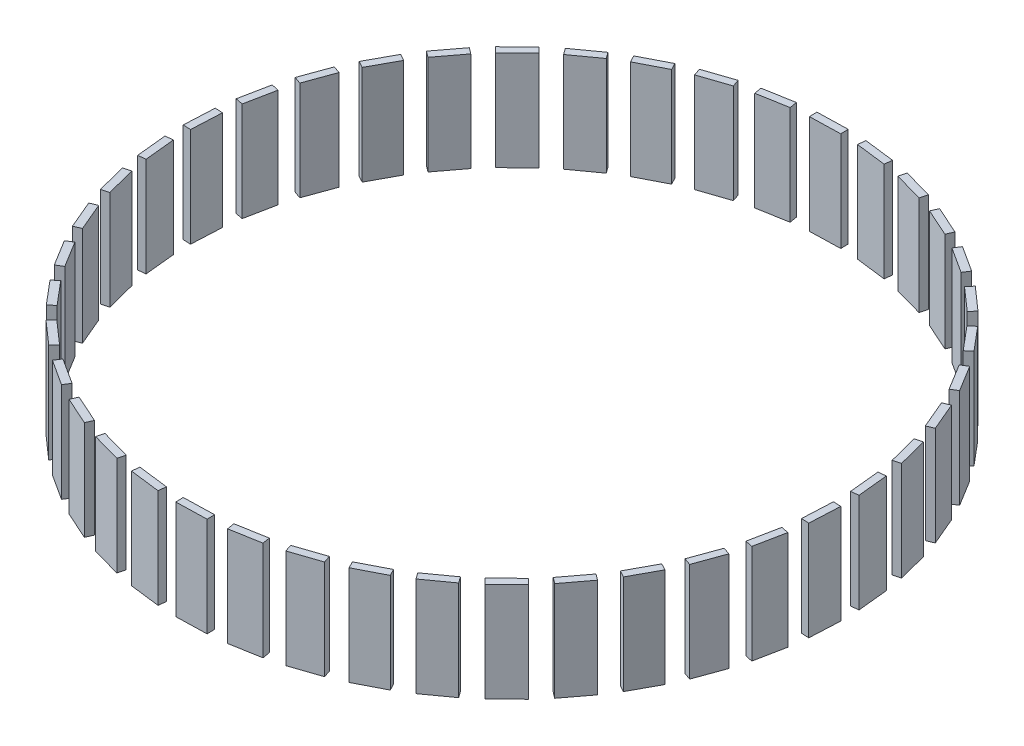
from build123d import *

# Parameters (mm, degrees)
SKETCH2_W           = 3.999993955
SKETCH2_H           = 13
BOSS_EXTRUDE1_DEPTH = 1
CIRPATTERN1_COUNT   = 42


with BuildPart() as part:
    # Sketch2 → Boss-Extrude1 (new body)
    with BuildSketch(Plane(origin=(54.639335118, 5.51e-07, -23.098494143), x_dir=(0.389380498, 3.69e-07, 0.921076993), z_dir=(-0.921076993, -9e-09, 0.389380498))):
        with Locations((82.503755349, 50.681860637)):
            Rectangle(SKETCH2_W, SKETCH2_H)
    extrude(amount=BOSS_EXTRUDE1_DEPTH)


with BuildPart() as cirpattern1_1:
    # CirPattern1: pattern copy
    add(part.part.rotate(Axis((47.084682439, 0, 69.668306924), (0, 1, 0)), 1 * 360 / CIRPATTERN1_COUNT))


with BuildPart() as cirpattern1_2:
    # CirPattern1: pattern copy
    add(part.part.rotate(Axis((47.084682439, 0, 69.668306924), (0, 1, 0)), 2 * 360 / CIRPATTERN1_COUNT))


with BuildPart() as cirpattern1_3:
    # CirPattern1: pattern copy
    add(part.part.rotate(Axis((47.084682439, 0, 69.668306924), (0, 1, 0)), 3 * 360 / CIRPATTERN1_COUNT))


with BuildPart() as cirpattern1_4:
    # CirPattern1: pattern copy
    add(part.part.rotate(Axis((47.084682439, 0, 69.668306924), (0, 1, 0)), 4 * 360 / CIRPATTERN1_COUNT))


with BuildPart() as cirpattern1_5:
    # CirPattern1: pattern copy
    add(part.part.rotate(Axis((47.084682439, 0, 69.668306924), (0, 1, 0)), 5 * 360 / CIRPATTERN1_COUNT))


with BuildPart() as cirpattern1_6:
    # CirPattern1: pattern copy
    add(part.part.rotate(Axis((47.084682439, 0, 69.668306924), (0, 1, 0)), 6 * 360 / CIRPATTERN1_COUNT))


with BuildPart() as cirpattern1_7:
    # CirPattern1: pattern copy
    add(part.part.rotate(Axis((47.084682439, 0, 69.668306924), (0, 1, 0)), 7 * 360 / CIRPATTERN1_COUNT))


with BuildPart() as cirpattern1_8:
    # CirPattern1: pattern copy
    add(part.part.rotate(Axis((47.084682439, 0, 69.668306924), (0, 1, 0)), 8 * 360 / CIRPATTERN1_COUNT))


with BuildPart() as cirpattern1_9:
    # CirPattern1: pattern copy
    add(part.part.rotate(Axis((47.084682439, 0, 69.668306924), (0, 1, 0)), 9 * 360 / CIRPATTERN1_COUNT))


with BuildPart() as cirpattern1_10:
    # CirPattern1: pattern copy
    add(part.part.rotate(Axis((47.084682439, 0, 69.668306924), (0, 1, 0)), 10 * 360 / CIRPATTERN1_COUNT))


with BuildPart() as cirpattern1_11:
    # CirPattern1: pattern copy
    add(part.part.rotate(Axis((47.084682439, 0, 69.668306924), (0, 1, 0)), 11 * 360 / CIRPATTERN1_COUNT))


with BuildPart() as cirpattern1_12:
    # CirPattern1: pattern copy
    add(part.part.rotate(Axis((47.084682439, 0, 69.668306924), (0, 1, 0)), 12 * 360 / CIRPATTERN1_COUNT))


with BuildPart() as cirpattern1_13:
    # CirPattern1: pattern copy
    add(part.part.rotate(Axis((47.084682439, 0, 69.668306924), (0, 1, 0)), 13 * 360 / CIRPATTERN1_COUNT))


with BuildPart() as cirpattern1_14:
    # CirPattern1: pattern copy
    add(part.part.rotate(Axis((47.084682439, 0, 69.668306924), (0, 1, 0)), 14 * 360 / CIRPATTERN1_COUNT))


with BuildPart() as cirpattern1_15:
    # CirPattern1: pattern copy
    add(part.part.rotate(Axis((47.084682439, 0, 69.668306924), (0, 1, 0)), 15 * 360 / CIRPATTERN1_COUNT))


with BuildPart() as cirpattern1_16:
    # CirPattern1: pattern copy
    add(part.part.rotate(Axis((47.084682439, 0, 69.668306924), (0, 1, 0)), 16 * 360 / CIRPATTERN1_COUNT))


with BuildPart() as cirpattern1_17:
    # CirPattern1: pattern copy
    add(part.part.rotate(Axis((47.084682439, 0, 69.668306924), (0, 1, 0)), 17 * 360 / CIRPATTERN1_COUNT))


with BuildPart() as cirpattern1_18:
    # CirPattern1: pattern copy
    add(part.part.rotate(Axis((47.084682439, 0, 69.668306924), (0, 1, 0)), 18 * 360 / CIRPATTERN1_COUNT))


with BuildPart() as cirpattern1_19:
    # CirPattern1: pattern copy
    add(part.part.rotate(Axis((47.084682439, 0, 69.668306924), (0, 1, 0)), 19 * 360 / CIRPATTERN1_COUNT))


with BuildPart() as cirpattern1_20:
    # CirPattern1: pattern copy
    add(part.part.rotate(Axis((47.084682439, 0, 69.668306924), (0, 1, 0)), 20 * 360 / CIRPATTERN1_COUNT))


with BuildPart() as cirpattern1_21:
    # CirPattern1: pattern copy
    add(part.part.rotate(Axis((47.084682439, 0, 69.668306924), (0, 1, 0)), 21 * 360 / CIRPATTERN1_COUNT))


with BuildPart() as cirpattern1_22:
    # CirPattern1: pattern copy
    add(part.part.rotate(Axis((47.084682439, 0, 69.668306924), (0, 1, 0)), 22 * 360 / CIRPATTERN1_COUNT))


with BuildPart() as cirpattern1_23:
    # CirPattern1: pattern copy
    add(part.part.rotate(Axis((47.084682439, 0, 69.668306924), (0, 1, 0)), 23 * 360 / CIRPATTERN1_COUNT))


with BuildPart() as cirpattern1_24:
    # CirPattern1: pattern copy
    add(part.part.rotate(Axis((47.084682439, 0, 69.668306924), (0, 1, 0)), 24 * 360 / CIRPATTERN1_COUNT))


with BuildPart() as cirpattern1_25:
    # CirPattern1: pattern copy
    add(part.part.rotate(Axis((47.084682439, 0, 69.668306924), (0, 1, 0)), 25 * 360 / CIRPATTERN1_COUNT))


with BuildPart() as cirpattern1_26:
    # CirPattern1: pattern copy
    add(part.part.rotate(Axis((47.084682439, 0, 69.668306924), (0, 1, 0)), 26 * 360 / CIRPATTERN1_COUNT))


with BuildPart() as cirpattern1_27:
    # CirPattern1: pattern copy
    add(part.part.rotate(Axis((47.084682439, 0, 69.668306924), (0, 1, 0)), 27 * 360 / CIRPATTERN1_COUNT))


with BuildPart() as cirpattern1_28:
    # CirPattern1: pattern copy
    add(part.part.rotate(Axis((47.084682439, 0, 69.668306924), (0, 1, 0)), 28 * 360 / CIRPATTERN1_COUNT))


with BuildPart() as cirpattern1_29:
    # CirPattern1: pattern copy
    add(part.part.rotate(Axis((47.084682439, 0, 69.668306924), (0, 1, 0)), 29 * 360 / CIRPATTERN1_COUNT))


with BuildPart() as cirpattern1_30:
    # CirPattern1: pattern copy
    add(part.part.rotate(Axis((47.084682439, 0, 69.668306924), (0, 1, 0)), 30 * 360 / CIRPATTERN1_COUNT))


with BuildPart() as cirpattern1_31:
    # CirPattern1: pattern copy
    add(part.part.rotate(Axis((47.084682439, 0, 69.668306924), (0, 1, 0)), 31 * 360 / CIRPATTERN1_COUNT))


with BuildPart() as cirpattern1_32:
    # CirPattern1: pattern copy
    add(part.part.rotate(Axis((47.084682439, 0, 69.668306924), (0, 1, 0)), 32 * 360 / CIRPATTERN1_COUNT))


with BuildPart() as cirpattern1_33:
    # CirPattern1: pattern copy
    add(part.part.rotate(Axis((47.084682439, 0, 69.668306924), (0, 1, 0)), 33 * 360 / CIRPATTERN1_COUNT))


with BuildPart() as cirpattern1_34:
    # CirPattern1: pattern copy
    add(part.part.rotate(Axis((47.084682439, 0, 69.668306924), (0, 1, 0)), 34 * 360 / CIRPATTERN1_COUNT))


with BuildPart() as cirpattern1_35:
    # CirPattern1: pattern copy
    add(part.part.rotate(Axis((47.084682439, 0, 69.668306924), (0, 1, 0)), 35 * 360 / CIRPATTERN1_COUNT))


with BuildPart() as cirpattern1_36:
    # CirPattern1: pattern copy
    add(part.part.rotate(Axis((47.084682439, 0, 69.668306924), (0, 1, 0)), 36 * 360 / CIRPATTERN1_COUNT))


with BuildPart() as cirpattern1_37:
    # CirPattern1: pattern copy
    add(part.part.rotate(Axis((47.084682439, 0, 69.668306924), (0, 1, 0)), 37 * 360 / CIRPATTERN1_COUNT))


with BuildPart() as cirpattern1_38:
    # CirPattern1: pattern copy
    add(part.part.rotate(Axis((47.084682439, 0, 69.668306924), (0, 1, 0)), 38 * 360 / CIRPATTERN1_COUNT))


with BuildPart() as cirpattern1_39:
    # CirPattern1: pattern copy
    add(part.part.rotate(Axis((47.084682439, 0, 69.668306924), (0, 1, 0)), 39 * 360 / CIRPATTERN1_COUNT))


with BuildPart() as cirpattern1_40:
    # CirPattern1: pattern copy
    add(part.part.rotate(Axis((47.084682439, 0, 69.668306924), (0, 1, 0)), 40 * 360 / CIRPATTERN1_COUNT))


with BuildPart() as cirpattern1_41:
    # CirPattern1: pattern copy
    add(part.part.rotate(Axis((47.084682439, 0, 69.668306924), (0, 1, 0)), 41 * 360 / CIRPATTERN1_COUNT))


solid = Compound([part.part, cirpattern1_1.part, cirpattern1_2.part, cirpattern1_3.part, cirpattern1_4.part, cirpattern1_5.part, cirpattern1_6.part, cirpattern1_7.part, cirpattern1_8.part, cirpattern1_9.part, cirpattern1_10.part, cirpattern1_11.part, cirpattern1_12.part, cirpattern1_13.part, cirpattern1_14.part, cirpattern1_15.part, cirpattern1_16.part, cirpattern1_17.part, cirpattern1_18.part, cirpattern1_19.part, cirpattern1_20.part, cirpattern1_21.part, cirpattern1_22.part, cirpattern1_23.part, cirpattern1_24.part, cirpattern1_25.part, cirpattern1_26.part, cirpattern1_27.part, cirpattern1_28.part, cirpattern1_29.part, cirpattern1_30.part, cirpattern1_31.part, cirpattern1_32.part, cirpattern1_33.part, cirpattern1_34.part, cirpattern1_35.part, cirpattern1_36.part, cirpattern1_37.part, cirpattern1_38.part, cirpattern1_39.part, cirpattern1_40.part, cirpattern1_41.part])
